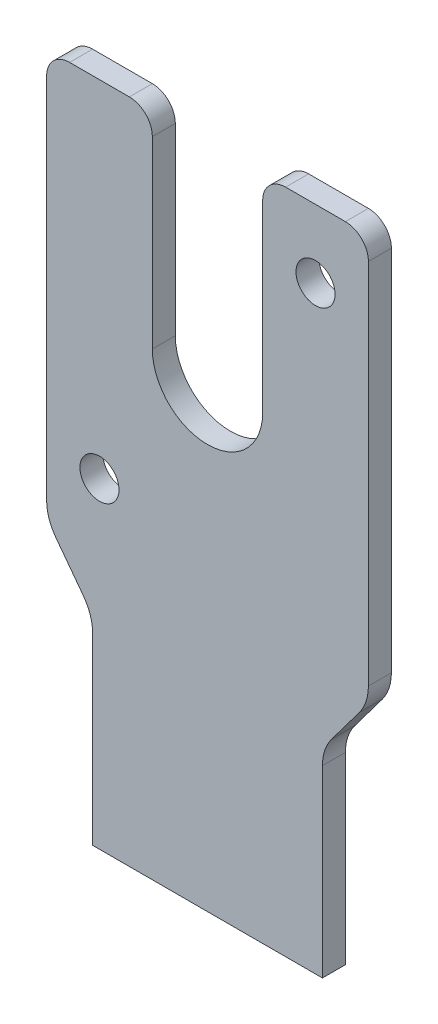
from build123d import *

# Parameters (mm, degrees)
BOSS_EXTRUDE1_DEPTH      = 5
TAP_DRILL_FOR_M10_TAP1_D = 8.5


with BuildPart() as part:
    # Sketch1 → Boss-Extrude1 (new body)
    with BuildSketch(Plane.XY):
        with BuildLine():
            Line((25, 0), (-25, 0))
            Line((-25, 0), (-25, 40))
            ThreePointArc((-25, 40), (-25.513167019, 43.16227766), (-27, 46))
            Line((-27, 46), (-33, 54))
            ThreePointArc((-33, 54), (-34.486832981, 56.83772234), (-35, 60))
            Line((-35, 60), (-35, 140))
            ThreePointArc((-35, 140), (-33.535533906, 143.535533906), (-30, 145))
            Line((-30, 145), (-17, 145))
            ThreePointArc((-17, 145), (-13.464466094, 143.535533906), (-12, 140))
            Line((-12, 140), (-12, 100))
            ThreePointArc((-12, 100), (0, 88), (12, 100))
            Line((12, 100), (12, 140))
            ThreePointArc((12, 140), (13.464466094, 143.535533906), (17, 145))
            Line((17, 145), (30, 145))
            ThreePointArc((30, 145), (33.535533906, 143.535533906), (35, 140))
            Line((35, 140), (35, 60))
            ThreePointArc((35, 60), (34.486832981, 56.83772234), (33, 54))
            Line((33, 54), (27, 46))
            ThreePointArc((27, 46), (25.513167019, 43.16227766), (25, 40))
            Line((25, 40), (25, 0))
        make_face()
    extrude(amount=BOSS_EXTRUDE1_DEPTH)

    # Tap Drill for M10 Tap1 (through all)
    with Locations(Plane.XY.offset(5)):
        with Locations((23.5, 130.17967031), (-23.5, 69.82032969)):
            Hole(TAP_DRILL_FOR_M10_TAP1_D / 2)


solid = part.part
